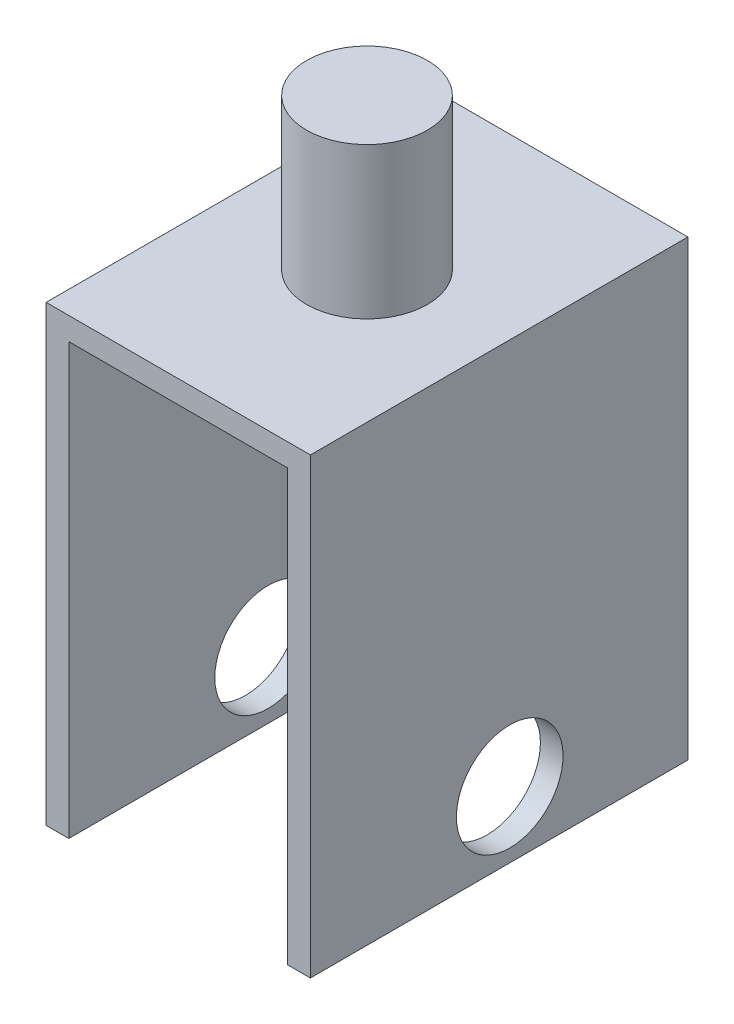
from build123d import *

# Parameters (mm, degrees)
BOSS_EXTRUDE2_DEPTH = 25
SKETCH4_R           = 8
BOSS_EXTRUDE3_DEPTH = 20
SKETCH5_R           = 7.061522099
CUT_EXTRUDE2_DEPTH  = 36


with BuildPart() as part:
    # Sketch3 → Boss-Extrude2 (new body, symmetric)
    with BuildSketch(Plane.XY):
        Polygon((14.5, -30), (17.5, -30), (17.5, 30), (-17.5, 30), (-17.5, -30), (-14.5, -30), (-14.5, 27), (14.5, 27), align=None)
    extrude(amount=BOSS_EXTRUDE2_DEPTH, both=True)

    # Sketch4 → Boss-Extrude3 (add)
    with BuildSketch(Plane(origin=(0, 30, 0), x_dir=(1, 0, 0), z_dir=(0, 1, 0))):
        Circle(SKETCH4_R)
    extrude(amount=BOSS_EXTRUDE3_DEPTH)

    # Sketch5 → Cut-Extrude2 (cut, through all)
    with BuildSketch(Plane.ZY.offset(17.5)):
        with Locations((-1.403257922, -21.231511185)):
            Circle(SKETCH5_R)
    extrude(amount=-CUT_EXTRUDE2_DEPTH, mode=Mode.SUBTRACT)


solid = part.part
